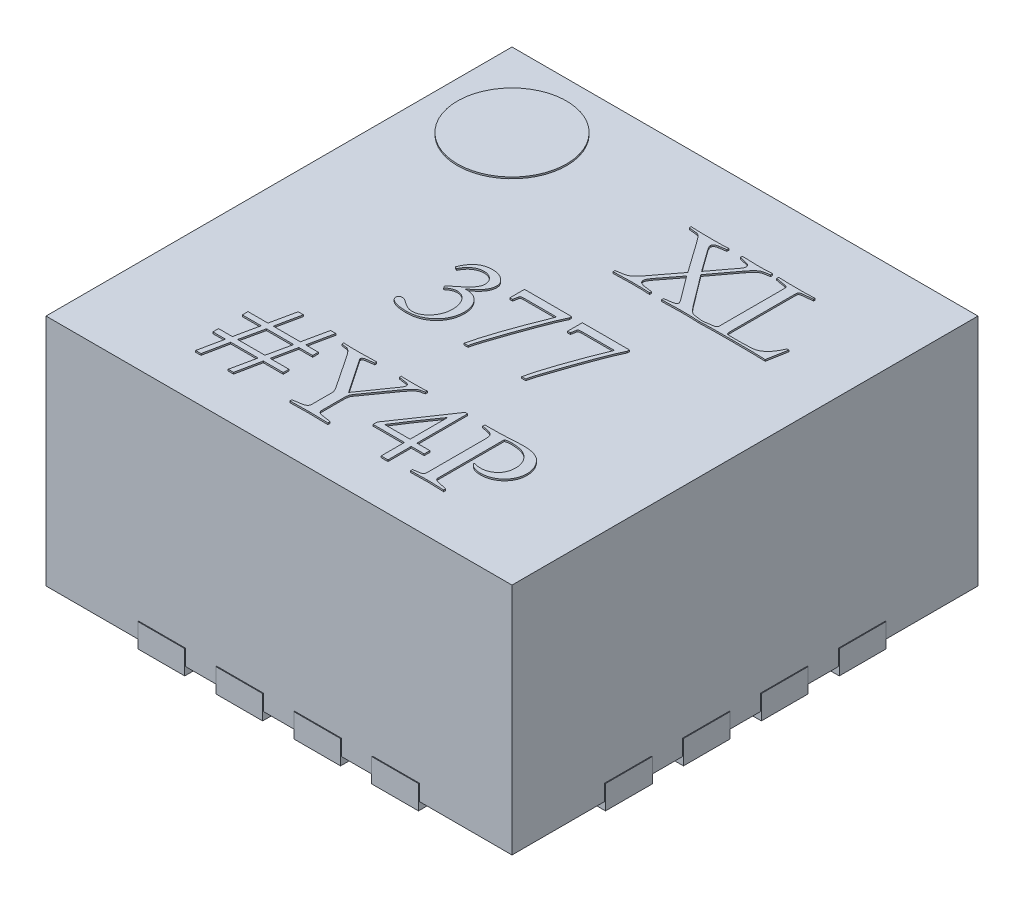
from build123d import *

# Parameters (mm, degrees)
SKETCH_361_W       = 2.99
SKETCH_361_H       = 2.99
EXTRUDE_1_DEPTH    = 1.5
EXTRUDE_2_DEPTH    = 0.152
EXTRUDE_2_2_DEPTH  = 0.152
EXTRUDE_2_3_DEPTH  = 0.152
EXTRUDE_2_4_DEPTH  = 0.152
EXTRUDE_2_5_DEPTH  = 0.152
EXTRUDE_2_6_DEPTH  = 0.152
EXTRUDE_2_7_DEPTH  = 0.152
EXTRUDE_2_8_DEPTH  = 0.152
EXTRUDE_2_9_DEPTH  = 0.152
EXTRUDE_2_10_DEPTH = 0.152
EXTRUDE_2_11_DEPTH = 0.152
EXTRUDE_2_12_DEPTH = 0.152
EXTRUDE_2_13_DEPTH = 0.152
EXTRUDE_2_14_DEPTH = 0.152
EXTRUDE_2_15_DEPTH = 0.152
EXTRUDE_2_16_DEPTH = 0.152
EXTRUDE_6_DEPTH    = 0.01
SKETCH_3_R         = 0.35
EXTRUDE_7_DEPTH    = 0.01


with BuildPart() as part:
    # Sketch 361 → 凸台-拉伸1 (new body)
    with BuildSketch(Plane(origin=(0, 0, 0), x_dir=(1, 0, 0), z_dir=(0, 1, 0))):
        Rectangle(SKETCH_361_W, SKETCH_361_H)
    extrude(amount=-EXTRUDE_1_DEPTH)

    # Sketch 1448 → 凸台-拉伸6 (add)
    with BuildSketch(Plane(origin=(0, 0, 0), x_dir=(1, 0, 0), z_dir=(0, 1, 0))):
        with BuildLine():
            Line((0.249497088, 0.645919019), (0.347656597, 0.773162827))
            Line((0.347656597, 0.773162827), (0.461607972, 0.620015815))
            add(Edge.make_bspline(
                [(0.474105132, 0.594907885), (0.473900612, 0.596438031), (0.473424869, 0.59999736), (0.470893013, 0.605742018), (0.466807151, 0.612515022), (0.463457885, 0.617346968), (0.461607972, 0.620015815)],
                knots=[0, 0, 0, 0, 0.650702868, 1.51362457, 2.626690916, 4, 4, 4, 4], degree=3))
            add(Edge.make_bspline(
                [(0.435704768, 0.578320746), (0.439080209, 0.578819652), (0.445284488, 0.579736675), (0.453664334, 0.58141712), (0.460334629, 0.583127359), (0.465505253, 0.584747693), (0.469325987, 0.586725372), (0.472149516, 0.588985), (0.473710481, 0.591878812), (0.473974923, 0.59390849), (0.474105132, 0.594907885)],
                knots=[0, 0, 0, 0, 1.836411901, 3.375444596, 4.596566594, 5.544111299, 6.282703451, 6.903973164, 7.4603262, 8, 8, 8, 8], degree=3))
            Line((0.435704768, 0.578320746), (0.399576616, 0.573435492))
            Line((0.399576616, 0.573435492), (0.399576616, 0.560597501))
            add(Edge.make_bspline(
                [(0.51966296, 0.563778596), (0.500118796, 0.563633782), (0.460070018, 0.563337038), (0.420060917, 0.561525164), (0.399576616, 0.560597501)],
                knots=[0, 0, 0, 0, 0.97601794, 2, 2, 2, 2], degree=3))
            add(Edge.make_bspline(
                [(0.639862914, 0.560597501), (0.631267794, 0.561081046), (0.613138184, 0.562100982), (0.58450346, 0.563097359), (0.553028666, 0.56362993), (0.531099959, 0.563727637), (0.51966296, 0.563778596)],
                knots=[0, 0, 0, 0, 0.858991602, 1.811863278, 2.858769037, 4, 4, 4, 4], degree=3))
            Line((0.639862914, 0.560597501), (0.63906764, 0.571731334))
            Line((0.63906764, 0.571731334), (0.639862914, 0.571845125))
            Line((0.639862914, 0.571845125), (0.639862914, 0.573208271))
            Line((0.639862914, 0.573208271), (0.589533444, 0.580365736))
            add(Edge.make_bspline(
                [(0.535341215, 0.627059669), (0.537970862, 0.623634868), (0.54297471, 0.617117956), (0.55046267, 0.608052252), (0.557726618, 0.600326962), (0.564646241, 0.593808032), (0.57124841, 0.588484143), (0.577560594, 0.584489989), (0.583600467, 0.581696632), (0.587619949, 0.580794974), (0.589533444, 0.580365736)],
                knots=[0, 0, 0, 0, 1.419864902, 2.701802293, 3.864678782, 4.904339743, 5.826201135, 6.648573279, 7.356646549, 8, 8, 8, 8], degree=3))
            Line((0.535341215, 0.627059669), (0.386170572, 0.825650898))
            Line((0.386170572, 0.825650898), (0.505575252, 0.985387322))
            add(Edge.make_bspline(
                [(0.56999243, 1.040829267), (0.567697815, 1.040253043), (0.562817832, 1.039027581), (0.555542657, 1.035621646), (0.54799551, 1.030749973), (0.540193038, 1.024386712), (0.531864005, 1.016815345), (0.523383559, 1.007582051), (0.514410859, 0.997096789), (0.508600978, 0.989397192), (0.505575252, 0.985387322)],
                knots=[0, 0, 0, 0, 0.654309202, 1.391526675, 2.212331248, 3.138139945, 4.177762206, 5.328315126, 6.608614123, 8, 8, 8, 8], degree=3))
            Line((0.56999243, 1.040829267), (0.610778615, 1.048668394))
            Line((0.610778615, 1.048668394), (0.610778615, 1.061392775))
            add(Edge.make_bspline(
                [(0.514209654, 1.05821168), (0.520193317, 1.058188072), (0.531630972, 1.058142947), (0.547914014, 1.058447146), (0.562533761, 1.05862119), (0.575447809, 1.058969628), (0.586699784, 1.05938066), (0.596236151, 1.060012754), (0.604099286, 1.060439555), (0.608736318, 1.061101315), (0.610778615, 1.061392775)],
                knots=[0, 0, 0, 0, 1.485431546, 2.839373144, 4.042907614, 5.115045725, 6.046550212, 6.837671103, 7.488073155, 8, 8, 8, 8], degree=3))
            add(Edge.make_bspline(
                [(0.416845418, 1.061392775), (0.424152793, 1.060911154), (0.43932765, 1.059910995), (0.462887521, 1.058905456), (0.48803877, 1.058363708), (0.505309906, 1.058263379), (0.514209654, 1.05821168)],
                knots=[0, 0, 0, 0, 0.901890839, 1.872911173, 2.903919603, 4, 4, 4, 4], degree=3))
            Line((0.416845418, 1.061392775), (0.416845418, 1.048668394))
            Line((0.416845418, 1.048668394), (0.461607972, 1.038443445))
            add(Edge.make_bspline(
                [(0.489101724, 1.014698842), (0.489013692, 1.01611012), (0.488843377, 1.018840506), (0.487514797, 1.022779328), (0.485296156, 1.026300842), (0.482296979, 1.029621726), (0.478192219, 1.032197732), (0.473527433, 1.034822783), (0.467846518, 1.036775558), (0.463772828, 1.037864667), (0.461607972, 1.038443445)],
                knots=[0, 0, 0, 0, 0.858139133, 1.660233573, 2.49862832, 3.379695956, 4.358260953, 5.431167193, 6.634861132, 8, 8, 8, 8], degree=3))
            add(Edge.make_bspline(
                [(0.478081501, 0.989363691), (0.479724877, 0.991639876), (0.482827544, 0.995937277), (0.486398371, 1.002494095), (0.48863676, 1.00872499), (0.488953188, 1.012790452), (0.489101724, 1.014698842)],
                knots=[0, 0, 0, 0, 1.198854206, 2.263416578, 3.184821569, 4, 4, 4, 4], degree=3))
            Line((0.478081501, 0.989363691), (0.370492317, 0.846214406))
            Line((0.370492317, 0.846214406), (0.271537534, 0.983796774))
            add(Edge.make_bspline(
                [(0.255064005, 1.019470485), (0.255301092, 1.017098408), (0.255829179, 1.011814859), (0.25933658, 1.003479714), (0.264540811, 0.993922616), (0.2690807, 0.987352368), (0.271537534, 0.983796774)],
                knots=[0, 0, 0, 0, 0.71561779, 1.593962999, 2.697934809, 4, 4, 4, 4], degree=3))
            add(Edge.make_bspline(
                [(0.282557756, 1.040829267), (0.280392654, 1.040447741), (0.276326914, 1.039731293), (0.270688194, 1.038197516), (0.265980681, 1.036109552), (0.261964645, 1.033756525), (0.258884572, 1.030779244), (0.256602911, 1.027389102), (0.25534224, 1.023531277), (0.255157992, 1.020842216), (0.255064005, 1.019470485)],
                knots=[0, 0, 0, 0, 1.378441976, 2.588509245, 3.651747828, 4.600659955, 5.490704415, 6.313943106, 7.139916816, 8, 8, 8, 8], degree=3))
            Line((0.282557756, 1.040829267), (0.330387795, 1.048668394))
            Line((0.330387795, 1.048668394), (0.330387795, 1.061392775))
            add(Edge.make_bspline(
                [(0.243248508, 1.05821168), (0.252034717, 1.058260822), (0.268586622, 1.058353399), (0.291920948, 1.058883241), (0.312192435, 1.059840824), (0.324671731, 1.06090523), (0.330387795, 1.061392775)],
                knots=[0, 0, 0, 0, 1.208737435, 2.277080784, 3.210827612, 4, 4, 4, 4], degree=3))
            add(Edge.make_bspline(
                [(0.087829285, 1.061392775), (0.091917979, 1.06110331), (0.100732825, 1.060479252), (0.115020125, 1.060019545), (0.131338842, 1.059396197), (0.14974572, 1.058974714), (0.170195881, 1.058623656), (0.192729764, 1.058450483), (0.217306757, 1.058144048), (0.234386774, 1.058188576), (0.243248508, 1.05821168)],
                knots=[0, 0, 0, 0, 0.632669679, 1.363977337, 2.206277886, 3.153583935, 4.205971639, 5.363496413, 6.63208596, 8, 8, 8, 8], degree=3))
            Line((0.087829285, 1.061392775), (0.087829285, 1.049463668))
            Line((0.087829285, 1.049463668), (0.140430967, 1.04366953))
            add(Edge.make_bspline(
                [(0.189056279, 0.99765726), (0.185817872, 1.00198892), (0.179930134, 1.009864297), (0.171767028, 1.020261677), (0.165363518, 1.028243022), (0.160085128, 1.033824903), (0.155493383, 1.037876551), (0.150722976, 1.040539357), (0.145784465, 1.042772133), (0.142233429, 1.043367387), (0.140430967, 1.04366953)],
                knots=[0, 0, 0, 0, 1.889416429, 3.435141614, 4.619311559, 5.461545026, 6.118855199, 6.747439537, 7.364215783, 8, 8, 8, 8], degree=3))
            Line((0.189056279, 0.99765726), (0.331978342, 0.796225767))
            Line((0.331978342, 0.796225767), (0.212687272, 0.63989766))
            add(Edge.make_bspline(
                [(0.138045145, 0.58127462), (0.141288245, 0.582066705), (0.147786758, 0.583653883), (0.157128139, 0.587472905), (0.166121317, 0.592433877), (0.174894111, 0.598720421), (0.183766207, 0.606542487), (0.193064782, 0.615995754), (0.202794836, 0.627303292), (0.209274939, 0.635553312), (0.212687272, 0.63989766)],
                knots=[0, 0, 0, 0, 0.824411809, 1.65195414, 2.485827372, 3.358680484, 4.314274634, 5.406615617, 6.634359139, 8, 8, 8, 8], degree=3))
            Line((0.138045145, 0.58127462), (0.087829285, 0.573321882))
            Line((0.087829285, 0.573321882), (0.087829285, 0.560597501))
            add(Edge.make_bspline(
                [(0.204734534, 0.563778596), (0.194433644, 0.56372578), (0.174209035, 0.563622082), (0.144438546, 0.563079135), (0.115768476, 0.562051261), (0.097030598, 0.561076273), (0.087829285, 0.560597501)],
                knots=[0, 0, 0, 0, 1.056840118, 2.074983654, 3.054712702, 4, 4, 4, 4], degree=3))
            add(Edge.make_bspline(
                [(0.321753394, 0.560597501), (0.318005603, 0.560885795), (0.310175126, 0.561488145), (0.297932445, 0.56195375), (0.284757725, 0.562579222), (0.270630325, 0.563009737), (0.255519792, 0.563363022), (0.239423466, 0.56353503), (0.222383004, 0.563844746), (0.210718179, 0.563801024), (0.204734534, 0.563778596)],
                knots=[0, 0, 0, 0, 0.770405764, 1.609653324, 2.510938987, 3.473989208, 4.506663828, 5.609047633, 6.773525579, 8, 8, 8, 8], degree=3))
            Line((0.321753394, 0.560597501), (0.321753394, 0.573435492))
            Line((0.321753394, 0.573435492), (0.273923355, 0.57911602))
            add(Edge.make_bspline(
                [(0.233023559, 0.608995592), (0.233158937, 0.606846752), (0.233422196, 0.602668073), (0.236023541, 0.596880349), (0.239992186, 0.591818791), (0.245561447, 0.587846892), (0.251990682, 0.584663915), (0.258927112, 0.582065845), (0.266256758, 0.580047817), (0.271336305, 0.579430449), (0.273923355, 0.57911602)],
                knots=[0, 0, 0, 0, 0.923927692, 1.796688635, 2.694128803, 3.676407027, 4.723402779, 5.790681206, 6.874778012, 8, 8, 8, 8], degree=3))
            add(Edge.make_bspline(
                [(0.249497088, 0.645919019), (0.247040822, 0.642441607), (0.242471178, 0.635972223), (0.237117006, 0.626302835), (0.233767923, 0.61739008), (0.233257181, 0.611630234), (0.233023559, 0.608995592)],
                knots=[0, 0, 0, 0, 1.244293502, 2.314886152, 3.229203092, 4, 4, 4, 4], degree=3))
        make_face()
        Polygon((0.63906764, 0.571731334), (0.639862914, 0.560597501), (0.639862914, 0.571845125), align=None)
        with BuildLine():
            Line((0.639862914, 0.571845125), (0.639862914, 0.560597501))
            add(Edge.make_bspline(
                [(0.852882682, 0.563778596), (0.839893129, 0.563802336), (0.815087764, 0.563847669), (0.779641806, 0.563541319), (0.747678533, 0.563368944), (0.719199992, 0.563019434), (0.694203818, 0.562605496), (0.672734309, 0.561975724), (0.654736323, 0.561537994), (0.643913899, 0.560888392), (0.639862914, 0.560597501)],
                knots=[0, 0, 0, 0, 1.457710228, 2.783701293, 3.977948958, 5.044746044, 5.979875062, 6.783384175, 7.455201995, 8, 8, 8, 8], degree=3))
            add(Edge.make_bspline(
                [(1.064198293, 0.560597501), (1.058405065, 0.560887034), (1.04595201, 0.561509409), (1.02598708, 0.561963568), (1.003456873, 0.562592559), (0.978347544, 0.563014234), (0.950626388, 0.563366187), (0.920329407, 0.563538106), (0.887458667, 0.563846466), (0.864698263, 0.563801789), (0.852882682, 0.563778596)],
                knots=[0, 0, 0, 0, 0.658624273, 1.415771075, 2.267489142, 3.217996841, 4.267333609, 5.415528701, 6.658326522, 8, 8, 8, 8], degree=3))
            Line((1.064198293, 0.560597501), (1.086920401, 0.689091025))
            Line((1.086920401, 0.689091025), (1.074423241, 0.689091025))
            add(Edge.make_bspline(
                [(0.891396657, 0.578320746), (0.89685019, 0.578340377), (0.907303965, 0.578378008), (0.922264765, 0.578719677), (0.935865207, 0.579259914), (0.948018021, 0.58008872), (0.958834656, 0.580895758), (0.968178204, 0.582204519), (0.976216231, 0.583454826), (0.985177679, 0.585768546), (0.995603207, 0.590003245), (1.007746272, 0.597182055), (1.019921254, 0.606764397), (1.032122226, 0.618575666), (1.044147254, 0.63267861), (1.055114771, 0.649379726), (1.065634481, 0.668217102), (1.071414427, 0.681944879), (1.074423241, 0.689091025)],
                knots=[0, 0, 0, 0, 1.115791484, 2.138839796, 3.061708793, 3.900288117, 4.631267422, 5.280005048, 5.830302646, 6.294493744, 7.170744433, 8.122248719, 9.171515836, 10.333253934, 11.592238097, 12.954717109, 14.41474433, 16, 16, 16, 16], degree=3))
            Line((0.891396657, 0.578320746), (0.818345077, 0.578320746))
            add(Edge.make_bspline(
                [(0.796418243, 0.599225086), (0.796579279, 0.596198838), (0.79686529, 0.590824062), (0.798833545, 0.584291659), (0.802542946, 0.580911522), (0.806687135, 0.579448704), (0.812046901, 0.578452204), (0.816103763, 0.578367528), (0.818345077, 0.578320746)],
                knots=[0, 0, 0, 0, 1.52547831, 2.709330726, 3.273463713, 3.971123529, 4.879096884, 6, 6, 6, 6], degree=3))
            Line((0.796418243, 0.599225086), (0.796418243, 1.017993547))
            add(Edge.make_bspline(
                [(0.81675453, 1.04366953), (0.814972103, 1.043387853), (0.811648203, 1.042862575), (0.807103888, 1.04183269), (0.803530046, 1.040323521), (0.800559795, 1.038588205), (0.798372556, 1.035551654), (0.797429649, 1.031019113), (0.796400501, 1.025084327), (0.796411872, 1.020539699), (0.796418243, 1.017993547)],
                knots=[0, 0, 0, 0, 1.129147415, 2.105654475, 2.901795765, 3.552129975, 4.229502502, 5.166434557, 6.412480253, 8, 8, 8, 8], degree=3))
            Line((0.81675453, 1.04366953), (0.884352803, 1.050940605))
            Line((0.884352803, 1.050940605), (0.884352803, 1.060597501))
            add(Edge.make_bspline(
                [(0.813687045, 1.05821168), (0.817701278, 1.058204311), (0.825464844, 1.05819006), (0.836637665, 1.058288545), (0.846899158, 1.058555424), (0.8561796, 1.058740624), (0.864551338, 1.059072646), (0.871969967, 1.059559281), (0.878492613, 1.059955114), (0.882498372, 1.060394221), (0.884352803, 1.060597501)],
                knots=[0, 0, 0, 0, 1.361966767, 2.634057224, 3.790729595, 4.844639865, 5.783389823, 6.632962862, 7.367142336, 8, 8, 8, 8], degree=3))
            add(Edge.make_bspline(
                [(0.650087863, 1.060597501), (0.65402576, 1.060393181), (0.662731468, 1.05994148), (0.677013332, 1.059560908), (0.693787696, 1.059059941), (0.712989372, 1.058744345), (0.734689808, 1.058551493), (0.75881262, 1.058289316), (0.785435814, 1.058189299), (0.80399228, 1.058204), (0.813687045, 1.05821168)],
                knots=[0, 0, 0, 0, 0.578330051, 1.278543367, 2.095349793, 3.039753367, 4.095157396, 5.27830747, 6.578060716, 8, 8, 8, 8], degree=3))
            Line((0.650087863, 1.060597501), (0.650087863, 1.04787312))
            Line((0.650087863, 1.04787312), (0.710528672, 1.037648171))
            add(Edge.make_bspline(
                [(0.73097857, 1.01231302), (0.730911718, 1.014588562), (0.730789617, 1.018744719), (0.729991849, 1.024318911), (0.728467385, 1.028681545), (0.725172992, 1.032735513), (0.719012734, 1.035994351), (0.713561271, 1.037057019), (0.710528672, 1.037648171)],
                knots=[0, 0, 0, 0, 1.102771303, 2.014153366, 2.723202657, 3.310900298, 4.504078668, 6, 6, 6, 6], degree=3))
            Line((0.73097857, 1.01231302), (0.73097857, 0.598543422))
            add(Edge.make_bspline(
                [(0.710528672, 0.581956283), (0.713567575, 0.582429426), (0.718995585, 0.583274541), (0.725862303, 0.586694285), (0.730385022, 0.592031929), (0.730778083, 0.596343991), (0.73097857, 0.598543422)],
                knots=[0, 0, 0, 0, 1.26151806, 2.253291469, 3.109065532, 4, 4, 4, 4], degree=3))
            Line((0.710528672, 0.581956283), (0.639862914, 0.571845125))
        make_face()
        with BuildLine():
            Line((-0.445458604, 0.082524336), (-0.431257286, 0.074685208))
            add(Edge.make_bspline(
                [(-0.328439744, 0.149327335), (-0.33360801, 0.149067852), (-0.343912237, 0.148550507), (-0.359190031, 0.144930893), (-0.373882067, 0.138633303), (-0.38810426, 0.130270764), (-0.401291281, 0.119597837), (-0.412985342, 0.106654195), (-0.42323348, 0.09163938), (-0.428529797, 0.080448348), (-0.431257286, 0.074685208)],
                knots=[0, 0, 0, 0, 0.921559953, 1.83735979, 2.78189872, 3.763014506, 4.771438712, 5.794593087, 6.864263113, 8, 8, 8, 8], degree=3))
            add(Edge.make_bspline(
                [(-0.253002344, 0.077866304), (-0.253253734, 0.08300506), (-0.253738762, 0.092919649), (-0.257782687, 0.107054281), (-0.2647818, 0.119474856), (-0.274331631, 0.130054308), (-0.285752046, 0.138666608), (-0.298785187, 0.144954856), (-0.313205979, 0.148629947), (-0.323268164, 0.149090585), (-0.328439744, 0.149327335)],
                knots=[0, 0, 0, 0, 1.057779911, 2.040854075, 2.998282636, 3.971142118, 4.957649127, 5.928063683, 6.935103482, 8, 8, 8, 8], degree=3))
            add(Edge.make_bspline(
                [(-0.339459967, -0.029722881), (-0.332666095, -0.024602055), (-0.319714348, -0.014839781), (-0.302067735, 0.000129915), (-0.287114734, 0.014523696), (-0.274860106, 0.028262545), (-0.265160381, 0.041364724), (-0.258428802, 0.05404205), (-0.25389916, 0.066091494), (-0.253290425, 0.074083919), (-0.253002344, 0.077866304)],
                knots=[0, 0, 0, 0, 1.437043954, 2.739561503, 3.906864101, 4.940252529, 5.84760448, 6.651838764, 7.361987852, 8, 8, 8, 8], degree=3))
            add(Edge.make_bspline(
                [(-0.373997572, -0.058011906), (-0.368507505, -0.053268456), (-0.357243182, -0.043536015), (-0.345486575, -0.034404056), (-0.339459967, -0.029722881)],
                knots=[0, 0, 0, 0, 0.974770768, 2, 2, 2, 2], degree=3))
            Line((-0.373997572, -0.058011906), (-0.365363171, -0.072894887))
            add(Edge.make_bspline(
                [(-0.305604025, -0.046196409), (-0.310531782, -0.046544357), (-0.320667138, -0.047260011), (-0.33571344, -0.052762144), (-0.351011149, -0.061078795), (-0.360410218, -0.068817096), (-0.365363171, -0.072894887)],
                knots=[0, 0, 0, 0, 0.883700942, 1.817586395, 2.849950896, 4, 4, 4, 4], degree=3))
            add(Edge.make_bspline(
                [(-0.218464739, -0.161738332), (-0.218508256, -0.157644695), (-0.218593896, -0.149588578), (-0.219914954, -0.13782621), (-0.221854323, -0.126598146), (-0.224389657, -0.11587886), (-0.227947461, -0.10574042), (-0.23228819, -0.096185187), (-0.237279986, -0.087137402), (-0.243053188, -0.078787433), (-0.249399712, -0.07117682), (-0.256164618, -0.064459833), (-0.263403957, -0.05879686), (-0.271103544, -0.054247849), (-0.279144363, -0.050534079), (-0.287662457, -0.048114572), (-0.296482291, -0.046376365), (-0.302527582, -0.046257102), (-0.305604025, -0.046196409)],
                knots=[0, 0, 0, 0, 1.217927062, 2.39683297, 3.518061248, 4.608958703, 5.671352245, 6.710648831, 7.730007538, 8.743113986, 9.727464929, 10.676052293, 11.575756505, 12.455392566, 13.333293357, 14.203561664, 15.085794228, 16, 16, 16, 16], degree=3))
            add(Edge.make_bspline(
                [(-0.339459967, -0.304660395), (-0.335513171, -0.304524287), (-0.327685966, -0.30425436), (-0.316179419, -0.302252115), (-0.304967023, -0.299092822), (-0.294247999, -0.294351083), (-0.283762314, -0.288541767), (-0.273770669, -0.281295125), (-0.264052503, -0.272839911), (-0.254859776, -0.263168419), (-0.246413976, -0.252543892), (-0.238837582, -0.24132474), (-0.232585637, -0.229360573), (-0.227356125, -0.216950284), (-0.223335851, -0.203932858), (-0.220530324, -0.190390399), (-0.218776345, -0.17625075), (-0.218569744, -0.166628749), (-0.218464739, -0.161738332)],
                knots=[0, 0, 0, 0, 0.913244864, 1.811128569, 2.696210262, 3.603291044, 4.517797354, 5.466579312, 6.45456648, 7.496283342, 8.550503968, 9.593584794, 10.624958559, 11.67021067, 12.70726923, 13.773270438, 14.868256433, 16, 16, 16, 16], degree=3))
            add(Edge.make_bspline(
                [(-0.413988483, -0.271599727), (-0.41041447, -0.274208508), (-0.403522686, -0.279239031), (-0.393152213, -0.285986279), (-0.383170652, -0.291669215), (-0.373621088, -0.296370974), (-0.364511399, -0.300033817), (-0.355831862, -0.30274436), (-0.347501897, -0.304241017), (-0.342077948, -0.30452387), (-0.339459967, -0.304660395)],
                knots=[0, 0, 0, 0, 1.282315491, 2.472693951, 3.583604925, 4.609553611, 5.555275528, 6.426814912, 7.240669544, 8, 8, 8, 8], degree=3))
            add(Edge.make_bspline(
                [(-0.44466333, -0.257512019), (-0.442334305, -0.257719187), (-0.437359381, -0.258161708), (-0.429799672, -0.260973208), (-0.42188832, -0.265551539), (-0.416745652, -0.269488814), (-0.413988483, -0.271599727)],
                knots=[0, 0, 0, 0, 0.814105265, 1.73897359, 2.78778303, 4, 4, 4, 4], degree=3))
            add(Edge.make_bspline(
                [(-0.468180712, -0.27864358), (-0.46809404, -0.277344177), (-0.467920843, -0.274747589), (-0.466451546, -0.270948854), (-0.463962507, -0.267452972), (-0.459839185, -0.263006551), (-0.453429791, -0.258639507), (-0.447492966, -0.257875949), (-0.44466333, -0.257512019)],
                knots=[0, 0, 0, 0, 0.677350117, 1.353543358, 2.094381632, 2.906315108, 4.525474315, 6, 6, 6, 6], degree=3))
            add(Edge.make_bspline(
                [(-0.357524043, -0.321929197), (-0.361879602, -0.321876827), (-0.370367189, -0.321774775), (-0.382686599, -0.321239867), (-0.394213503, -0.320234375), (-0.40489793, -0.318744953), (-0.414795047, -0.316940532), (-0.423919755, -0.31482158), (-0.432250151, -0.312229902), (-0.439703987, -0.309158022), (-0.446363658, -0.305872956), (-0.452095297, -0.302350943), (-0.457105876, -0.298868041), (-0.461098657, -0.295099066), (-0.464252937, -0.291222277), (-0.466458755, -0.287136522), (-0.467904851, -0.28294319), (-0.468090123, -0.280055516), (-0.468180712, -0.27864358)],
                knots=[0, 0, 0, 0, 1.637325206, 3.190621759, 4.634099991, 5.984969185, 7.244223978, 8.414738773, 9.504286158, 10.519405068, 11.442517159, 12.292124775, 13.046738326, 13.731521556, 14.349576546, 14.916498181, 15.470219064, 16, 16, 16, 16], degree=3))
            add(Edge.make_bspline(
                [(-0.165067783, -0.14049316), (-0.165193625, -0.146714625), (-0.16544187, -0.158987603), (-0.168221085, -0.177003578), (-0.172311393, -0.194320769), (-0.178345021, -0.210857079), (-0.185931461, -0.226690452), (-0.195357063, -0.241770274), (-0.206403447, -0.25614165), (-0.219109249, -0.269532536), (-0.232946684, -0.281928332), (-0.24801871, -0.292635337), (-0.264030385, -0.301654776), (-0.280932023, -0.309059081), (-0.298726464, -0.314904497), (-0.317502028, -0.318933123), (-0.337190702, -0.321527201), (-0.350661114, -0.321793515), (-0.357524043, -0.321929197)],
                knots=[0, 0, 0, 0, 1.009437024, 1.991299377, 2.953318579, 3.894815576, 4.843714236, 5.799324309, 6.777172901, 7.782104325, 8.792758158, 9.789281548, 10.777822791, 11.771857457, 12.781144618, 13.813675569, 14.886107574, 16, 16, 16, 16], degree=3))
            add(Edge.make_bspline(
                [(-0.291516318, -0.010181867), (-0.286858692, -0.009980214), (-0.277761617, -0.009586353), (-0.264425342, -0.010485636), (-0.251770042, -0.012763793), (-0.239839089, -0.016397984), (-0.228614587, -0.021296747), (-0.218135614, -0.027535396), (-0.20836244, -0.035035292), (-0.199404762, -0.043804483), (-0.191397305, -0.053561045), (-0.184322084, -0.064003899), (-0.178390822, -0.075138121), (-0.173429917, -0.086902254), (-0.169764355, -0.099423228), (-0.16699979, -0.112520527), (-0.165404065, -0.12629042), (-0.165181756, -0.135679576), (-0.165067783, -0.14049316)],
                knots=[0, 0, 0, 0, 1.082943028, 2.115157825, 3.09922867, 4.065383794, 5.007340602, 5.938710501, 6.89288378, 7.863878008, 8.845465863, 9.821949798, 10.790667459, 11.773083675, 12.783911744, 13.817926263, 14.88130577, 16, 16, 16, 16], degree=3))
            add(Edge.make_bspline(
                [(-0.205967579, 0.10842754), (-0.206184789, 0.103362125), (-0.20661955, 0.093223339), (-0.21091602, 0.078358633), (-0.217435332, 0.063856181), (-0.226827214, 0.049698464), (-0.238931806, 0.035475855), (-0.253849392, 0.020780148), (-0.271435614, 0.005153583), (-0.28459005, -0.00489234), (-0.291516318, -0.010181867)],
                knots=[0, 0, 0, 0, 0.799876415, 1.601009369, 2.429889356, 3.309322563, 4.279330444, 5.381248455, 6.621136216, 8, 8, 8, 8], degree=3))
            add(Edge.make_bspline(
                [(-0.309580394, 0.185682709), (-0.305979342, 0.185630292), (-0.298909826, 0.185527387), (-0.288546556, 0.184332748), (-0.278635727, 0.182529509), (-0.269148145, 0.180062832), (-0.260159396, 0.176729905), (-0.25155392, 0.172735717), (-0.243398745, 0.167999918), (-0.235839687, 0.162497325), (-0.228802271, 0.156739191), (-0.222814591, 0.15043503), (-0.217617851, 0.144056991), (-0.213338959, 0.137408166), (-0.210078829, 0.130477775), (-0.207593603, 0.123338936), (-0.206241481, 0.115939665), (-0.20605889, 0.110931868), (-0.205967579, 0.10842754)],
                knots=[0, 0, 0, 0, 1.210049366, 2.375545844, 3.501719123, 4.594882723, 5.666256486, 6.719935501, 7.781125016, 8.830410954, 9.860601074, 10.833004002, 11.747601428, 12.623454581, 13.4833402, 14.316711343, 15.158211241, 16, 16, 16, 16], degree=3))
            add(Edge.make_bspline(
                [(-0.445458604, 0.082524336), (-0.443529751, 0.086898471), (-0.439769185, 0.095426456), (-0.433596738, 0.107578535), (-0.427296233, 0.118931392), (-0.420451261, 0.12916678), (-0.413536766, 0.138651749), (-0.406122593, 0.147014237), (-0.3985146, 0.154556206), (-0.390596529, 0.161236958), (-0.382252178, 0.167092266), (-0.373367176, 0.172070749), (-0.363990322, 0.1763302), (-0.35407226, 0.179677877), (-0.343687799, 0.182463175), (-0.332775459, 0.18434859), (-0.321346373, 0.185525491), (-0.313559769, 0.185629536), (-0.309580394, 0.185682709)],
                knots=[0, 0, 0, 0, 1.253152087, 2.443194228, 3.572538399, 4.654809403, 5.669570356, 6.647522894, 7.58133273, 8.476328969, 9.360520028, 10.249714409, 11.142946455, 12.056692672, 12.991135742, 13.959158542, 14.957019917, 16, 16, 16, 16], degree=3))
        make_face()
        with BuildLine():
            Line((0.204166482, 0.178411634), (-0.098151174, 0.178411634))
            Line((-0.098151174, 0.178411634), (-0.098151174, 0.084342105))
            Line((-0.098151174, 0.084342105), (-0.080882371, 0.084342105))
            Line((-0.080882371, 0.084342105), (-0.074633791, 0.117402773))
            add(Edge.make_bspline(
                [(-0.05338862, 0.127514111), (-0.056320317, 0.127397346), (-0.061462775, 0.127192531), (-0.068172072, 0.125548793), (-0.073102043, 0.122279269), (-0.074138183, 0.118980598), (-0.074633791, 0.117402773)],
                knots=[0, 0, 0, 0, 1.376594233, 2.414669022, 3.241701828, 4, 4, 4, 4], degree=3))
            Line((-0.05338862, 0.127514111), (0.158608654, 0.127514111))
            add(Edge.make_bspline(
                [(0.007052189, -0.315339786), (0.008698471, -0.308404687), (0.012069493, -0.294203979), (0.017632846, -0.272489694), (0.023917658, -0.249898654), (0.030752445, -0.226347272), (0.038110804, -0.201873681), (0.046062766, -0.176486041), (0.054741997, -0.150229249), (0.063971196, -0.123022547), (0.073502456, -0.09479992), (0.084126782, -0.065853976), (0.094917999, -0.035828578), (0.106567643, -0.004961996), (0.118703084, 0.026857392), (0.131475462, 0.059596846), (0.144680518, 0.093314007), (0.153924395, 0.11601206), (0.158608654, 0.127514111)],
                knots=[0, 0, 0, 0, 0.730271412, 1.495345808, 2.296408786, 3.132623017, 4.007822776, 4.91468434, 5.858221513, 6.841021025, 7.858204703, 8.910022558, 9.999958302, 11.127077164, 12.290093979, 13.489051424, 14.727597593, 16, 16, 16, 16], degree=3))
            Line((0.007052189, -0.315339786), (0.032955393, -0.315339786))
            add(Edge.make_bspline(
                [(0.204166482, 0.164210316), (0.202982302, 0.161981323), (0.200431405, 0.15717974), (0.196565936, 0.149355232), (0.192542102, 0.140313417), (0.187932738, 0.13026369), (0.183244543, 0.119000412), (0.178064648, 0.106682673), (0.17265086, 0.093183851), (0.166881614, 0.078556141), (0.160695905, 0.062821571), (0.154276263, 0.045947452), (0.147443649, 0.02796532), (0.140226133, 0.008876515), (0.132965581, -0.011457453), (0.125023535, -0.032789032), (0.11700638, -0.055315802), (0.108741714, -0.078578247), (0.100449817, -0.101766527), (0.092615139, -0.124200779), (0.085235583, -0.145447654), (0.078265007, -0.16553035), (0.071956773, -0.184496712), (0.066012778, -0.202245764), (0.060582081, -0.218802688), (0.055570646, -0.234173766), (0.05098298, -0.248350307), (0.047056507, -0.261405302), (0.043497161, -0.273247935), (0.040438961, -0.283930369), (0.03779223, -0.293418536), (0.035755586, -0.301763651), (0.034122387, -0.308915098), (0.033320471, -0.313329912), (0.032955393, -0.315339786)],
                knots=[0, 0, 0, 0, 0.475319071, 1.023907632, 1.643056695, 2.338941327, 3.105894381, 3.940308846, 4.855426282, 5.84471047, 6.901557499, 8.039289191, 9.244617828, 10.524225064, 11.882368977, 13.310589347, 14.810716466, 16.385202183, 17.959687899, 19.448328098, 20.860234011, 22.195414489, 23.45159444, 24.624327872, 25.720391861, 26.733024678, 27.669024094, 28.526318295, 29.300269, 29.997759746, 30.618877231, 31.155087906, 31.615348152, 32, 32, 32, 32], degree=3))
            Line((0.204166482, 0.164210316), (0.204166482, 0.178411634))
        make_face()
        with BuildLine():
            Line((0.574991294, 0.178411634), (0.272673639, 0.178411634))
            Line((0.272673639, 0.178411634), (0.272673639, 0.084342105))
            Line((0.272673639, 0.084342105), (0.289942442, 0.084342105))
            Line((0.289942442, 0.084342105), (0.296191021, 0.117402773))
            add(Edge.make_bspline(
                [(0.317436193, 0.127514111), (0.314504496, 0.127397346), (0.309362037, 0.127192531), (0.30265274, 0.125548793), (0.29772277, 0.122279269), (0.29668663, 0.118980598), (0.296191021, 0.117402773)],
                knots=[0, 0, 0, 0, 1.376594233, 2.414669022, 3.241701828, 4, 4, 4, 4], degree=3))
            Line((0.317436193, 0.127514111), (0.529433466, 0.127514111))
            add(Edge.make_bspline(
                [(0.377877002, -0.315339786), (0.379523284, -0.308404687), (0.382894305, -0.294203979), (0.388457658, -0.272489694), (0.394742471, -0.249898654), (0.401577258, -0.226347272), (0.408935616, -0.201873681), (0.416887578, -0.176486041), (0.425566809, -0.150229249), (0.434796008, -0.123022547), (0.444327269, -0.09479992), (0.454951594, -0.065853976), (0.465742811, -0.035828578), (0.477392456, -0.004961996), (0.489527897, 0.026857392), (0.502300275, 0.059596846), (0.51550533, 0.093314007), (0.524749208, 0.11601206), (0.529433466, 0.127514111)],
                knots=[0, 0, 0, 0, 0.730271412, 1.495345808, 2.296408786, 3.132623017, 4.007822776, 4.91468434, 5.858221513, 6.841021025, 7.858204703, 8.910022558, 9.999958302, 11.127077164, 12.290093979, 13.489051424, 14.727597593, 16, 16, 16, 16], degree=3))
            Line((0.377877002, -0.315339786), (0.403780206, -0.315339786))
            add(Edge.make_bspline(
                [(0.574991294, 0.164210316), (0.573807115, 0.161981323), (0.571256218, 0.15717974), (0.567390749, 0.149355232), (0.563366914, 0.140313417), (0.558757551, 0.13026369), (0.554069356, 0.119000412), (0.54888946, 0.106682673), (0.543475673, 0.093183851), (0.537706427, 0.078556141), (0.531520718, 0.062821571), (0.525101076, 0.045947452), (0.518268461, 0.02796532), (0.511050945, 0.008876515), (0.503790393, -0.011457453), (0.495848348, -0.032789032), (0.487831192, -0.055315802), (0.479566527, -0.078578247), (0.47127463, -0.101766527), (0.463439951, -0.124200779), (0.456060395, -0.145447654), (0.44908982, -0.16553035), (0.442781585, -0.184496712), (0.436837591, -0.202245764), (0.431406893, -0.218802688), (0.426395459, -0.234173766), (0.421807793, -0.248350307), (0.417881319, -0.261405302), (0.414321974, -0.273247935), (0.411263773, -0.283930369), (0.408617042, -0.293418536), (0.406580398, -0.301763651), (0.404947199, -0.308915098), (0.404145283, -0.313329912), (0.403780206, -0.315339786)],
                knots=[0, 0, 0, 0, 0.475319071, 1.023907632, 1.643056695, 2.338941327, 3.105894381, 3.940308846, 4.855426282, 5.84471047, 6.901557499, 8.039289191, 9.244617828, 10.524225064, 11.882368977, 13.310589347, 14.810716466, 16.385202183, 17.959687899, 19.448328098, 20.860234011, 22.195414489, 23.45159444, 24.624327872, 25.720391861, 26.733024678, 27.669024094, 28.526318295, 29.300269, 29.997759746, 30.618877231, 31.155087906, 31.615348152, 32, 32, 32, 32], degree=3))
            Line((0.574991294, 0.164210316), (0.574991294, 0.178411634))
        make_face()
        Polygon((-0.733574941, -0.832267757), (-0.861614023, -0.832267757), (-0.861614023, -0.868623131), (-0.740732405, -0.868623131), (-0.772884189, -1.0213157), (-0.861614023, -1.0213157), (-0.861614023, -1.057671074), (-0.780723316, -1.057671074), (-0.813670374, -1.216271392), (-0.779132769, -1.216271392), (-0.746980985, -1.057671074), (-0.571111864, -1.057671074), (-0.604854196, -1.216271392), (-0.57031659, -1.216271392), (-0.538051196, -1.057671074), (-0.410125725, -1.057671074), (-0.410125725, -1.0213157), (-0.531007343, -1.0213157), (-0.498855559, -0.868623131), (-0.410125725, -0.868623131), (-0.410125725, -0.832267757), (-0.491698095, -0.832267757), (-0.457955763, -0.672076891), (-0.491698095, -0.672076891), (-0.525554037, -0.832267757), (-0.69983261, -0.832267757), (-0.666090278, -0.672076891), (-0.69983261, -0.672076891), align=None)
        Polygon((-0.739937131, -1.020520427), (-0.706876463, -0.868623131), (-0.531802616, -0.868623131), (-0.564749674, -1.020520427), align=None, mode=Mode.SUBTRACT)
        with BuildLine():
            Line((0.01341438, -1.180029629), (-0.045435882, -1.171395228))
            add(Edge.make_bspline(
                [(-0.076110728, -1.143901476), (-0.076047706, -1.145733273), (-0.075927157, -1.149237121), (-0.074321303, -1.154165586), (-0.071949611, -1.158611511), (-0.068421304, -1.162335594), (-0.064125245, -1.165687301), (-0.058654511, -1.168034393), (-0.052400015, -1.170145202), (-0.047837616, -1.170964129), (-0.045435882, -1.171395228)],
                knots=[0, 0, 0, 0, 0.961790014, 1.839704466, 2.706650269, 3.597190743, 4.523718184, 5.559944095, 6.715507673, 8, 8, 8, 8], degree=3))
            Line((-0.076110728, -1.143901476), (-0.076110728, -1.015180731))
            add(Edge.make_bspline(
                [(-0.065090505, -0.957807407), (-0.066970386, -0.96088398), (-0.070861659, -0.967252356), (-0.073624879, -0.976672758), (-0.074871431, -0.98550313), (-0.075661735, -0.993920136), (-0.076079275, -1.004004692), (-0.076099749, -1.011279721), (-0.076110728, -1.015180731)],
                knots=[0, 0, 0, 0, 1.089625713, 2.255478605, 2.940781304, 3.794277571, 4.817249401, 6, 6, 6, 6], degree=3))
            Line((-0.065090505, -0.957807407), (0.061358029, -0.780347739))
            add(Edge.make_bspline(
                [(0.128161028, -0.716725835), (0.12605028, -0.71721224), (0.12145582, -0.718270996), (0.114544154, -0.721924848), (0.10722191, -0.72741737), (0.099118979, -0.73447607), (0.090565395, -0.74345213), (0.081180225, -0.754021226), (0.071388606, -0.76654024), (0.064812546, -0.775592454), (0.061358029, -0.780347739)],
                knots=[0, 0, 0, 0, 0.551537198, 1.20052926, 1.976550585, 2.888481301, 3.942080599, 5.141614265, 6.498440612, 8, 8, 8, 8], degree=3))
            Line((0.128161028, -0.716725835), (0.154859506, -0.710590865))
            Line((0.154859506, -0.710590865), (0.154859506, -0.698207316))
            add(Edge.make_bspline(
                [(0.072378252, -0.701388411), (0.077490932, -0.701412086), (0.087262447, -0.701457334), (0.101197325, -0.701151813), (0.113696697, -0.700980309), (0.124717358, -0.700631782), (0.134303521, -0.700215806), (0.142437736, -0.699588019), (0.149168955, -0.699161165), (0.153120636, -0.698498785), (0.154859506, -0.698207316)],
                knots=[0, 0, 0, 0, 1.485372276, 2.838890355, 4.049393725, 5.117171527, 6.042450453, 6.836556904, 7.488046525, 8, 8, 8, 8], degree=3))
            add(Edge.make_bspline(
                [(-0.010898276, -0.69900259), (-0.009954355, -0.699211079), (-0.007374674, -0.699780868), (-0.00233683, -0.700049532), (0.004808776, -0.700577104), (0.014133133, -0.700860805), (0.025645831, -0.701057481), (0.039316749, -0.701314806), (0.055147163, -0.701410974), (0.066394756, -0.701396246), (0.072378252, -0.701388411)],
                knots=[0, 0, 0, 0, 0.277914274, 0.759522705, 1.447649292, 2.342104263, 3.443290257, 4.762454476, 6.277690244, 8, 8, 8, 8], degree=3))
            Line((-0.010898276, -0.69900259), (-0.010898276, -0.711386139))
            Line((-0.010898276, -0.711386139), (0.039431194, -0.719111656))
            add(Edge.make_bspline(
                [(0.058972208, -0.736380458), (0.058752308, -0.734193433), (0.058322774, -0.72992148), (0.054132624, -0.724430219), (0.047545214, -0.720802188), (0.042320116, -0.719713554), (0.039431194, -0.719111656)],
                knots=[0, 0, 0, 0, 0.906355962, 1.77039979, 2.767268645, 4, 4, 4, 4], degree=3))
            add(Edge.make_bspline(
                [(0.047270322, -0.76387421), (0.049043923, -0.761184943), (0.052330935, -0.75620093), (0.055874139, -0.748802661), (0.058526703, -0.742389275), (0.058833186, -0.738255542), (0.058972208, -0.736380458)],
                knots=[0, 0, 0, 0, 1.275886913, 2.364598779, 3.258173344, 4, 4, 4, 4], degree=3))
            Line((0.047270322, -0.76387421), (-0.089403162, -0.958602681))
            Line((-0.089403162, -0.958602681), (-0.236528815, -0.741833765))
            add(Edge.make_bspline(
                [(-0.23970991, -0.733199363), (-0.239530061, -0.734592627), (-0.239128665, -0.737702194), (-0.237453442, -0.740364387), (-0.236528815, -0.741833765)],
                knots=[0, 0, 0, 0, 0.896114687, 2, 2, 2, 2], degree=3))
            add(Edge.make_bspline(
                [(-0.218464739, -0.718316382), (-0.221612384, -0.718899813), (-0.227168466, -0.71992966), (-0.234098326, -0.72302082), (-0.238895947, -0.727502408), (-0.239443034, -0.731331487), (-0.23970991, -0.733199363)],
                knots=[0, 0, 0, 0, 1.357529886, 2.396250728, 3.217669187, 4, 4, 4, 4], degree=3))
            Line((-0.218464739, -0.718316382), (-0.169044152, -0.711386139))
            Line((-0.169044152, -0.711386139), (-0.169044152, -0.69900259))
            add(Edge.make_bspline(
                [(-0.274247515, -0.701388411), (-0.268377639, -0.701395998), (-0.257054327, -0.701410633), (-0.240693684, -0.701309404), (-0.225622203, -0.701045836), (-0.211836066, -0.700855401), (-0.199337123, -0.700530094), (-0.18809269, -0.700033111), (-0.17812676, -0.699644743), (-0.1719215, -0.699206022), (-0.169044152, -0.69900259)],
                knots=[0, 0, 0, 0, 1.338497528, 2.582034893, 3.730681976, 4.775716319, 5.725970994, 6.58157985, 7.342285664, 8, 8, 8, 8], degree=3))
            add(Edge.make_bspline(
                [(-0.380246152, -0.69900259), (-0.378543532, -0.699209446), (-0.374391989, -0.699713828), (-0.366954138, -0.700055833), (-0.357225995, -0.700556357), (-0.345141741, -0.700862789), (-0.330712151, -0.701052607), (-0.31393623, -0.701314315), (-0.294848998, -0.701410617), (-0.281367106, -0.701396085), (-0.274247515, -0.701388411)],
                knots=[0, 0, 0, 0, 0.387990574, 0.946047343, 1.683801983, 2.592509193, 3.68094247, 4.949311445, 6.388975692, 8, 8, 8, 8], degree=3))
            Line((-0.380246152, -0.69900259), (-0.380246152, -0.711386139))
            Line((-0.380246152, -0.711386139), (-0.345708547, -0.715930561))
            add(Edge.make_bspline(
                [(-0.295492687, -0.765464757), (-0.297995197, -0.761729432), (-0.302740642, -0.754646233), (-0.310025401, -0.744938769), (-0.316968831, -0.736708687), (-0.323256004, -0.729607274), (-0.329420035, -0.724155997), (-0.335114411, -0.719979914), (-0.340434701, -0.717024328), (-0.344054782, -0.716273543), (-0.345708547, -0.715930561)],
                knots=[0, 0, 0, 0, 1.497798431, 2.840235824, 4.040497488, 5.085262741, 5.996826177, 6.774172856, 7.440004215, 8, 8, 8, 8], degree=3))
            Line((-0.295492687, -0.765464757), (-0.155638108, -0.975076209))
            add(Edge.make_bspline(
                [(-0.141550401, -1.014385457), (-0.141748445, -1.011302115), (-0.142160745, -1.004883037), (-0.144946326, -0.995140971), (-0.14946296, -0.985056754), (-0.153510435, -0.978515048), (-0.155638108, -0.975076209)],
                knots=[0, 0, 0, 0, 0.874305589, 1.820179423, 2.854113918, 4, 4, 4, 4], degree=3))
            Line((-0.141550401, -1.014385457), (-0.141550401, -1.145492024))
            add(Edge.make_bspline(
                [(-0.172225248, -1.172190502), (-0.170090884, -1.171750844), (-0.165901112, -1.170887793), (-0.160046731, -1.168750928), (-0.15478272, -1.165942757), (-0.150175456, -1.16262942), (-0.146426006, -1.158769895), (-0.143558008, -1.154630564), (-0.14192239, -1.150113427), (-0.141673254, -1.147018288), (-0.141550401, -1.145492024)],
                knots=[0, 0, 0, 0, 1.188248729, 2.33254074, 3.386664986, 4.436728646, 5.416060316, 6.310342439, 7.166801827, 8, 8, 8, 8], degree=3))
            Line((-0.172225248, -1.172190502), (-0.231075509, -1.181620177))
            Line((-0.231075509, -1.181620177), (-0.231075509, -1.194230947))
            add(Edge.make_bspline(
                [(-0.109739449, -1.191845126), (-0.120949176, -1.191857301), (-0.142650121, -1.191880873), (-0.174084889, -1.192333516), (-0.203322023, -1.193124386), (-0.222063059, -1.193871611), (-0.231075509, -1.194230947)],
                knots=[0, 0, 0, 0, 1.108313397, 2.14558727, 3.108224276, 4, 4, 4, 4], degree=3))
            add(Edge.make_bspline(
                [(0.01341438, -1.194230947), (0.006181378, -1.194033316), (-0.007678179, -1.193654624), (-0.027599829, -1.19324146), (-0.045700075, -1.192754993), (-0.062022108, -1.192399683), (-0.076489947, -1.192215746), (-0.089175161, -1.191948866), (-0.100044429, -1.191825473), (-0.106709817, -1.191838984), (-0.109739449, -1.191845126)],
                knots=[0, 0, 0, 0, 1.409775997, 2.701350475, 3.882279085, 4.93763652, 5.882199597, 6.701345854, 7.409720128, 8, 8, 8, 8], degree=3))
            Line((0.01341438, -1.194230947), (0.01341438, -1.180029629))
        make_face()
        Polygon((0.41105128, -0.695480663), (0.395145804, -0.695480663), (0.259835648, -0.894980777), (0.166447781, -1.031540649), (0.166447781, -1.057671074), (0.367424832, -1.057671074), (0.367424832, -1.206955328), (0.41105128, -1.206955328), (0.41105128, -1.057671074), (0.494327809, -1.057671074), (0.494327809, -1.0213157), (0.41105128, -1.0213157), align=None)
        with BuildLine():
            Line((0.367424832, -0.780234128), (0.367424832, -1.0213157))
            Line((0.367424832, -1.0213157), (0.204052871, -1.0213157))
            add(Edge.make_bspline(
                [(0.367424832, -0.780234128), (0.358767742, -0.792298637), (0.34190252, -0.815801987), (0.317660284, -0.850378698), (0.294737377, -0.883024562), (0.273638011, -0.914116145), (0.253974048, -0.943359596), (0.235903074, -0.970912869), (0.219277896, -0.996595305), (0.208985287, -1.013307091), (0.204052871, -1.0213157)],
                knots=[0, 0, 0, 0, 1.223474311, 2.383498995, 3.479359132, 4.510116583, 5.479380977, 6.382890926, 7.225050186, 8, 8, 8, 8], degree=3))
        make_face(mode=Mode.SUBTRACT)
        with BuildLine():
            add(Edge.make_bspline(
                [(0.52807014, -0.702410906), (0.534167271, -0.70242181), (0.545869345, -0.702442736), (0.562683558, -0.70229967), (0.577982907, -0.702178962), (0.591768952, -0.702115737), (0.604037603, -0.701839445), (0.614833247, -0.70166825), (0.624110249, -0.701305507), (0.629789567, -0.701049875), (0.632364618, -0.700933969)],
                knots=[0, 0, 0, 0, 1.402787605, 2.692336081, 3.868618828, 4.922923777, 5.864085495, 6.692000722, 7.406941965, 8, 8, 8, 8], degree=3))
            Line((0.52807014, -0.702410906), (0.52807014, -0.716725835))
            add(Edge.make_bspline(
                [(0.607370299, -0.771486116), (0.607200876, -0.766914245), (0.606885493, -0.75840364), (0.603368158, -0.746789386), (0.59742013, -0.737495565), (0.588660102, -0.730826209), (0.577406615, -0.726212328), (0.563618363, -0.72217595), (0.54682825, -0.718988567), (0.534632283, -0.717517405), (0.52807014, -0.716725835)],
                knots=[0, 0, 0, 0, 1.002949749, 1.867005304, 2.636259172, 3.389427713, 4.246955311, 5.298429119, 6.546396821, 8, 8, 8, 8], degree=3))
            Line((0.607370299, -0.771486116), (0.607370299, -1.146060077))
            add(Edge.make_bspline(
                [(0.587715675, -1.17593965), (0.589550268, -1.175502298), (0.592954382, -1.174690787), (0.597466712, -1.172764245), (0.601017641, -1.170387014), (0.60360703, -1.167314025), (0.605323837, -1.163417191), (0.606507785, -1.15857934), (0.607298461, -1.152674583), (0.607345178, -1.148373095), (0.607370299, -1.146060077)],
                knots=[0, 0, 0, 0, 1.124453281, 2.086439046, 2.914464613, 3.65272227, 4.451839652, 5.433553767, 6.619957388, 8, 8, 8, 8], degree=3))
            Line((0.587715675, -1.17593965), (0.543748395, -1.182188229))
            Line((0.543748395, -1.182188229), (0.543748395, -1.194799))
            add(Edge.make_bspline(
                [(0.650996747, -1.192413178), (0.648383684, -1.19240701), (0.642627141, -1.192393422), (0.633196889, -1.192518284), (0.622178106, -1.192782329), (0.609565759, -1.192969519), (0.595364371, -1.193321074), (0.579574563, -1.193811586), (0.562189869, -1.194222335), (0.550072479, -1.194601246), (0.543748395, -1.194799)],
                knots=[0, 0, 0, 0, 0.584581469, 1.287824707, 2.109802308, 3.050368616, 4.109697972, 5.287820614, 6.584509396, 8, 8, 8, 8], degree=3))
            add(Edge.make_bspline(
                [(0.757677047, -1.195594274), (0.747187544, -1.195127703), (0.727309341, -1.194243525), (0.699059737, -1.193173), (0.673986316, -1.192598315), (0.658305907, -1.192472039), (0.650996747, -1.192413178)],
                knots=[0, 0, 0, 0, 1.18046946, 2.237056585, 3.178233435, 4, 4, 4, 4], degree=3))
            Line((0.757677047, -1.195594274), (0.757677047, -1.182983503))
            Line((0.757677047, -1.182983503), (0.700303723, -1.170372733))
            add(Edge.make_bspline(
                [(0.672809972, -1.144469529), (0.672876467, -1.146291429), (0.673000719, -1.149695794), (0.673871256, -1.154432103), (0.675408648, -1.15840418), (0.677890578, -1.16162796), (0.681493162, -1.164268229), (0.686492439, -1.166403524), (0.692877025, -1.168559217), (0.697678782, -1.169731752), (0.700303723, -1.170372733)],
                knots=[0, 0, 0, 0, 1.02954616, 1.923789516, 2.710919312, 3.413124675, 4.19235518, 5.20755781, 6.473476532, 8, 8, 8, 8], degree=3))
            Line((0.672809972, -1.144469529), (0.672809972, -0.72206553))
            add(Edge.make_bspline(
                [(0.71439143, -0.715930561), (0.710108322, -0.715976316), (0.702054989, -0.716062347), (0.690810577, -0.71719294), (0.681114313, -0.718962199), (0.675439469, -0.721082888), (0.672809972, -0.72206553)],
                knots=[0, 0, 0, 0, 1.214676809, 2.283901129, 3.204828112, 4, 4, 4, 4], degree=3))
            add(Edge.make_bspline(
                [(0.865947895, -0.840788548), (0.865841544, -0.836541316), (0.865631758, -0.828163342), (0.863888209, -0.815869674), (0.861046375, -0.804068962), (0.85703882, -0.792767341), (0.851925706, -0.781878807), (0.845481313, -0.771565425), (0.838102033, -0.761623404), (0.829567305, -0.75226221), (0.819757018, -0.743680874), (0.808596169, -0.736155805), (0.796025722, -0.729925066), (0.782273199, -0.724670333), (0.767137405, -0.720743645), (0.750719561, -0.717942798), (0.73298402, -0.716231033), (0.720719703, -0.716032831), (0.71439143, -0.715930561)],
                knots=[0, 0, 0, 0, 0.917936167, 1.810696287, 2.678515635, 3.538263513, 4.398946578, 5.273805689, 6.16299182, 7.072859029, 8.007154595, 8.974551799, 9.974189615, 11.034078294, 12.152202097, 13.348867977, 14.632040765, 16, 16, 16, 16], degree=3))
            add(Edge.make_bspline(
                [(0.752905405, -0.956216859), (0.756810897, -0.956140561), (0.764537155, -0.955989619), (0.775828685, -0.954467727), (0.786673964, -0.952077692), (0.797016466, -0.948707525), (0.806850265, -0.944165391), (0.816275909, -0.938915497), (0.825125846, -0.932516592), (0.833467011, -0.925346398), (0.841111892, -0.917259924), (0.847799523, -0.908435413), (0.853464945, -0.898875381), (0.85794956, -0.888579965), (0.86167442, -0.877660874), (0.864068112, -0.865938747), (0.865764337, -0.853600539), (0.865885953, -0.845111954), (0.865947895, -0.840788548)],
                knots=[0, 0, 0, 0, 1.031983127, 2.041578265, 3.005877685, 3.965174761, 4.910578924, 5.865529936, 6.812893488, 7.792404837, 8.769764874, 9.748917999, 10.713892826, 11.699931602, 12.713045109, 13.75772247, 14.857963053, 16, 16, 16, 16], degree=3))
            add(Edge.make_bspline(
                [(0.710528672, -0.949173006), (0.713957676, -0.950260999), (0.720780297, -0.952425759), (0.731332672, -0.954508492), (0.742033575, -0.95597028), (0.749264784, -0.956134288), (0.752905405, -0.956216859)],
                knots=[0, 0, 0, 0, 0.99993529, 1.98955163, 2.987820823, 4, 4, 4, 4], degree=3))
            Line((0.710528672, -0.949173006), (0.705757029, -0.953944648))
            add(Edge.make_bspline(
                [(0.78119443, -0.984505885), (0.777175082, -0.984434826), (0.769372281, -0.98429688), (0.758078037, -0.982769786), (0.747540171, -0.980391327), (0.737677635, -0.977125418), (0.72855686, -0.972754973), (0.720075014, -0.967542344), (0.712390572, -0.96126967), (0.707970896, -0.956389288), (0.705757029, -0.953944648)],
                knots=[0, 0, 0, 0, 1.146093526, 2.224922935, 3.244504935, 4.225100062, 5.182016445, 6.123436179, 7.060007366, 8, 8, 8, 8], degree=3))
            add(Edge.make_bspline(
                [(0.934341442, -0.837721063), (0.934212111, -0.842726508), (0.933957234, -0.852590912), (0.931887265, -0.867109898), (0.9283381, -0.881033796), (0.923434554, -0.894401085), (0.917147784, -0.907193262), (0.90948067, -0.919400514), (0.900453707, -0.93107353), (0.890076056, -0.94192352), (0.878808912, -0.951931511), (0.866685613, -0.960556682), (0.854036349, -0.968039842), (0.840660898, -0.974076072), (0.826647118, -0.97874784), (0.812022689, -0.981991151), (0.796822647, -0.984142834), (0.786465935, -0.984383425), (0.78119443, -0.984505885)],
                knots=[0, 0, 0, 0, 1.016622244, 2.003492449, 2.971956735, 3.930993038, 4.890985555, 5.862287815, 6.854899511, 7.883475107, 8.908332062, 9.911826975, 10.901482374, 11.889701234, 12.887220621, 13.896978158, 14.929574335, 16, 16, 16, 16], degree=3))
            add(Edge.make_bspline(
                [(0.769378933, -0.694117336), (0.776465059, -0.694242563), (0.790138797, -0.694484205), (0.80987669, -0.696484845), (0.82802411, -0.700049026), (0.844748472, -0.704726457), (0.859899993, -0.710957289), (0.873525559, -0.718623238), (0.885506907, -0.727785788), (0.895992471, -0.738143288), (0.904851733, -0.74947563), (0.912746056, -0.761072561), (0.919494211, -0.772964225), (0.924873873, -0.785280189), (0.929078112, -0.797909675), (0.932154493, -0.810866342), (0.934052305, -0.824182814), (0.934244252, -0.833170349), (0.934341442, -0.837721063)],
                knots=[0, 0, 0, 0, 1.376693725, 2.65653619, 3.8485211, 4.966388251, 6.025408534, 7.023877494, 7.995189341, 8.94736016, 9.879329335, 10.785465574, 11.671694923, 12.53163036, 13.392572601, 14.254614686, 15.116248421, 16, 16, 16, 16], degree=3))
            add(Edge.make_bspline(
                [(0.745066277, -0.69491261), (0.749193212, -0.694695066), (0.757292179, -0.694268143), (0.765401717, -0.69416696), (0.769378933, -0.694117336)],
                knots=[0, 0, 0, 0, 1.019126244, 2, 2, 2, 2], degree=3))
            Line((0.745066277, -0.69491261), (0.632364618, -0.700933969))
        make_face()
    extrude(amount=EXTRUDE_6_DEPTH)


with BuildPart() as body_2:
    # Sketch 489 → 凸台-拉伸2 (new body)
    with BuildSketch(Plane(origin=(0, -1.55, 0), x_dir=(1, 0, 0), z_dir=(0, 1, 0))):
        with BuildLine():
            Line((0.1, 1.5), (0.1, 1.25))
            ThreePointArc((0.1, 1.25), (0.25, 1.1), (0.4, 1.25))
            Line((0.4, 1.25), (0.4, 1.5))
            Line((0.4, 1.5), (0.1, 1.5))
        make_face()
    extrude(amount=EXTRUDE_2_DEPTH)


with BuildPart() as body_3:
    # Sketch 489 → Extrude 2 2 (new body)
    with BuildSketch(Plane(origin=(0, -1.55, 0), x_dir=(1, 0, 0), z_dir=(0, 1, 0))):
        with BuildLine():
            Line((-0.4, 1.5), (-0.4, 1.25))
            ThreePointArc((-0.4, 1.25), (-0.25, 1.1), (-0.1, 1.25))
            Line((-0.1, 1.25), (-0.1, 1.5))
            Line((-0.1, 1.5), (-0.4, 1.5))
        make_face()
    extrude(amount=EXTRUDE_2_2_DEPTH)


with BuildPart() as body_4:
    # Sketch 489 → Extrude 2 3 (new body)
    with BuildSketch(Plane(origin=(0, -1.55, 0), x_dir=(1, 0, 0), z_dir=(0, 1, 0))):
        with BuildLine():
            Line((-0.6, -1.5), (-0.6, -1.25))
            ThreePointArc((-0.6, -1.25), (-0.75, -1.1), (-0.9, -1.25))
            Line((-0.9, -1.25), (-0.9, -1.5))
            Line((-0.9, -1.5), (-0.6, -1.5))
        make_face()
    extrude(amount=EXTRUDE_2_3_DEPTH)


with BuildPart() as body_5:
    # Sketch 489 → Extrude 2 4 (new body)
    with BuildSketch(Plane(origin=(0, -1.55, 0), x_dir=(1, 0, 0), z_dir=(0, 1, 0))):
        with BuildLine():
            Line((-0.9, 1.5), (-0.9, 1.25))
            ThreePointArc((-0.9, 1.25), (-0.75, 1.1), (-0.6, 1.25))
            Line((-0.6, 1.25), (-0.6, 1.5))
            Line((-0.6, 1.5), (-0.9, 1.5))
        make_face()
    extrude(amount=EXTRUDE_2_4_DEPTH)


with BuildPart() as body_6:
    # Sketch 489 → Extrude 2 5 (new body)
    with BuildSketch(Plane(origin=(0, -1.55, 0), x_dir=(1, 0, 0), z_dir=(0, 1, 0))):
        with BuildLine():
            Line((-1.5, -0.9), (-1.25, -0.9))
            ThreePointArc((-1.25, -0.9), (-1.1, -0.75), (-1.25, -0.6))
            Line((-1.25, -0.6), (-1.5, -0.6))
            Line((-1.5, -0.6), (-1.5, -0.9))
        make_face()
    extrude(amount=EXTRUDE_2_5_DEPTH)


with BuildPart() as body_7:
    # Sketch 489 → Extrude 2 6 (new body)
    with BuildSketch(Plane(origin=(0, -1.55, 0), x_dir=(1, 0, 0), z_dir=(0, 1, 0))):
        with BuildLine():
            Line((0.4, -1.5), (0.4, -1.25))
            ThreePointArc((0.4, -1.25), (0.25, -1.1), (0.1, -1.25))
            Line((0.1, -1.25), (0.1, -1.5))
            Line((0.1, -1.5), (0.4, -1.5))
        make_face()
    extrude(amount=EXTRUDE_2_6_DEPTH)


with BuildPart() as body_8:
    # Sketch 489 → Extrude 2 7 (new body)
    with BuildSketch(Plane(origin=(0, -1.55, 0), x_dir=(1, 0, 0), z_dir=(0, 1, 0))):
        with BuildLine():
            Line((0.9, -1.5), (0.9, -1.25))
            ThreePointArc((0.9, -1.25), (0.75, -1.1), (0.6, -1.25))
            Line((0.6, -1.25), (0.6, -1.5))
            Line((0.6, -1.5), (0.9, -1.5))
        make_face()
    extrude(amount=EXTRUDE_2_7_DEPTH)


with BuildPart() as body_9:
    # Sketch 489 → Extrude 2 8 (new body)
    with BuildSketch(Plane(origin=(0, -1.55, 0), x_dir=(1, 0, 0), z_dir=(0, 1, 0))):
        with BuildLine():
            Line((-1.5, 0.6), (-1.25, 0.6))
            ThreePointArc((-1.25, 0.6), (-1.1, 0.75), (-1.25, 0.9))
            Line((-1.25, 0.9), (-1.5, 0.9))
            Line((-1.5, 0.9), (-1.5, 0.6))
        make_face()
    extrude(amount=EXTRUDE_2_8_DEPTH)


with BuildPart() as body_10:
    # Sketch 489 → Extrude 2 9 (new body)
    with BuildSketch(Plane(origin=(0, -1.55, 0), x_dir=(1, 0, 0), z_dir=(0, 1, 0))):
        with BuildLine():
            Line((-0.1, -1.5), (-0.1, -1.25))
            ThreePointArc((-0.1, -1.25), (-0.25, -1.1), (-0.4, -1.25))
            Line((-0.4, -1.25), (-0.4, -1.5))
            Line((-0.4, -1.5), (-0.1, -1.5))
        make_face()
    extrude(amount=EXTRUDE_2_9_DEPTH)


with BuildPart() as body_11:
    # Sketch 489 → Extrude 2 10 (new body)
    with BuildSketch(Plane(origin=(0, -1.55, 0), x_dir=(1, 0, 0), z_dir=(0, 1, 0))):
        with BuildLine():
            Line((-1.5, -0.4), (-1.25, -0.4))
            ThreePointArc((-1.25, -0.4), (-1.1, -0.25), (-1.25, -0.1))
            Line((-1.25, -0.1), (-1.5, -0.1))
            Line((-1.5, -0.1), (-1.5, -0.4))
        make_face()
    extrude(amount=EXTRUDE_2_10_DEPTH)


with BuildPart() as body_12:
    # Sketch 489 → Extrude 2 11 (new body)
    with BuildSketch(Plane(origin=(0, -1.55, 0), x_dir=(1, 0, 0), z_dir=(0, 1, 0))):
        with BuildLine():
            Line((-1.5, 0.1), (-1.25, 0.1))
            ThreePointArc((-1.25, 0.1), (-1.1, 0.25), (-1.25, 0.4))
            Line((-1.25, 0.4), (-1.5, 0.4))
            Line((-1.5, 0.4), (-1.5, 0.1))
        make_face()
    extrude(amount=EXTRUDE_2_11_DEPTH)


with BuildPart() as body_13:
    # Sketch 489 → Extrude 2 12 (new body)
    with BuildSketch(Plane(origin=(0, -1.55, 0), x_dir=(1, 0, 0), z_dir=(0, 1, 0))):
        with BuildLine():
            Line((1.5, -0.6), (1.25, -0.6))
            ThreePointArc((1.25, -0.6), (1.1, -0.75), (1.25, -0.9))
            Line((1.25, -0.9), (1.5, -0.9))
            Line((1.5, -0.9), (1.5, -0.6))
        make_face()
    extrude(amount=EXTRUDE_2_12_DEPTH)


with BuildPart() as body_14:
    # Sketch 489 → Extrude 2 13 (new body)
    with BuildSketch(Plane(origin=(0, -1.55, 0), x_dir=(1, 0, 0), z_dir=(0, 1, 0))):
        with BuildLine():
            Line((1.5, -0.1), (1.25, -0.1))
            ThreePointArc((1.25, -0.1), (1.1, -0.25), (1.25, -0.4))
            Line((1.25, -0.4), (1.5, -0.4))
            Line((1.5, -0.4), (1.5, -0.1))
        make_face()
    extrude(amount=EXTRUDE_2_13_DEPTH)


with BuildPart() as body_15:
    # Sketch 489 → Extrude 2 14 (new body)
    with BuildSketch(Plane(origin=(0, -1.55, 0), x_dir=(1, 0, 0), z_dir=(0, 1, 0))):
        with BuildLine():
            Line((1.5, 0.4), (1.25, 0.4))
            ThreePointArc((1.25, 0.4), (1.1, 0.25), (1.25, 0.1))
            Line((1.25, 0.1), (1.5, 0.1))
            Line((1.5, 0.1), (1.5, 0.4))
        make_face()
    extrude(amount=EXTRUDE_2_14_DEPTH)


with BuildPart() as body_16:
    # Sketch 489 → Extrude 2 15 (new body)
    with BuildSketch(Plane(origin=(0, -1.55, 0), x_dir=(1, 0, 0), z_dir=(0, 1, 0))):
        with BuildLine():
            Line((1.5, 0.9), (1.25, 0.9))
            ThreePointArc((1.25, 0.9), (1.1, 0.75), (1.25, 0.6))
            Line((1.25, 0.6), (1.5, 0.6))
            Line((1.5, 0.6), (1.5, 0.9))
        make_face()
    extrude(amount=EXTRUDE_2_15_DEPTH)


with BuildPart() as body_17:
    # Sketch 489 → Extrude 2 16 (new body)
    with BuildSketch(Plane(origin=(0, -1.55, 0), x_dir=(1, 0, 0), z_dir=(0, 1, 0))):
        with BuildLine():
            Line((0.6, 1.5), (0.6, 1.25))
            ThreePointArc((0.6, 1.25), (0.75, 1.1), (0.9, 1.25))
            Line((0.9, 1.25), (0.9, 1.5))
            Line((0.9, 1.5), (0.6, 1.5))
        make_face()
    extrude(amount=EXTRUDE_2_16_DEPTH)


with BuildPart() as body_18:
    # 草图3 → 凸台-拉伸7 (new body)
    with BuildSketch(Plane(origin=(0, 0.01, 0), x_dir=(1, 0, 0), z_dir=(0, 1, 0))):
        with Locations(Location((-1, 1, 0), (0, 0, 270))):
            Circle(SKETCH_3_R)
    extrude(amount=EXTRUDE_7_DEPTH)


solid = Compound([part.part, body_2.part, body_3.part, body_4.part, body_5.part, body_6.part, body_7.part, body_8.part, body_9.part, body_10.part, body_11.part, body_12.part, body_13.part, body_14.part, body_15.part, body_16.part, body_17.part, body_18.part])
